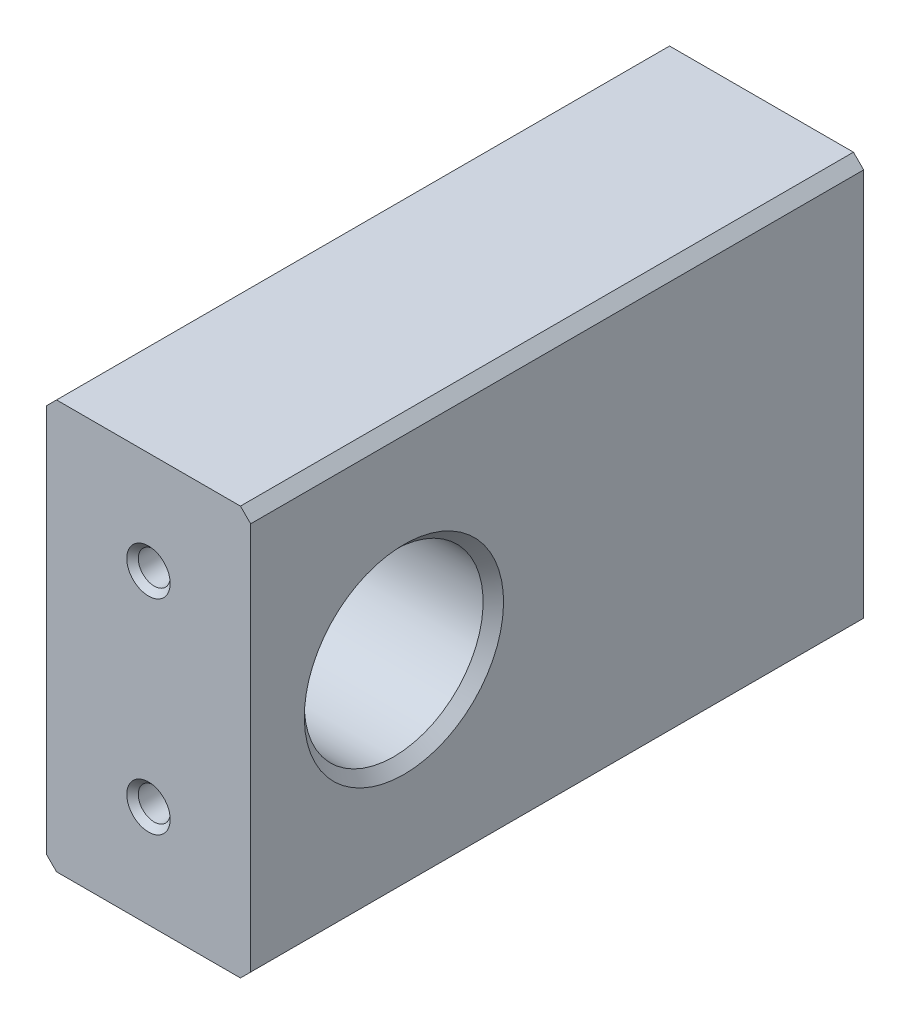
from build123d import *

# Parameters (mm, degrees)
SKETCH1_W                        = 50.8
SKETCH1_H                        = 101.6
EXTRUDE1_DEPTH                   = 152.4
SKETCH2_R                        = 22.225
EXTRUDE2_DEPTH                   = 51.8
CHAMFER1_SIZE                    = 2.54
F_3_8_16_TAPPED_HOLE1_AT_2_COUNT = 2
F_3_8_16_TAPPED_HOLE1_AT_2_PITCH = 50.8


with BuildPart() as part:
    # Sketch1 → Extrude1 (new body)
    with BuildSketch(Plane.XY):
        with Locations((25.4, 0)):
            Rectangle(SKETCH1_W, SKETCH1_H)
    extrude(amount=EXTRUDE1_DEPTH)

    # Sketch2 → Extrude2 (cut, through all)
    with BuildSketch(Plane(origin=(50.8, 0, 0), x_dir=(0, 0, -1), z_dir=(1, 0, 0))):
        with Locations(Location((-114.3, 0, 0), (0, 0, 90))):  # turned: the seam where the file's is
            Circle(SKETCH2_R)
    extrude(amount=-EXTRUDE2_DEPTH, mode=Mode.SUBTRACT)

    # Chamfer1
    chamfer1_edges = [part.edges().sort_by_distance(p)[0] for p in [
        (50.8, -22.225, 114.3),
        (50.8, -50.8, 76.2),
        (0, -50.8, 76.2),
        (0, 50.8, 76.2),
        (50.8, 50.8, 76.2),
    ]]
    chamfer(chamfer1_edges, length=CHAMFER1_SIZE)

    # Sketch3 → 3/8-16 Tapped Hole1 (revolve, cut)
    with BuildSketch(Plane(origin=(25.4, -25.4, 0), x_dir=(0, 1, 0), z_dir=(1, 0, 0))):
        Polygon((0, 0), (0, 26.260665582), (3.96875, 23.876), (3.96875, 1.42875), (5.3975, 0), align=None)
    f_3_8_16_tapped_hole1 = revolve(axis=Axis((25.4, -25.4, -6.35), (0, 0, 1)), mode=Mode.SUBTRACT)

    # 3/8-16 Tapped Hole1 at 2: 3/8-16 Tapped Hole1 ×2
    with Locations(*[(0, i * F_3_8_16_TAPPED_HOLE1_AT_2_PITCH, 0) for i in range(1, F_3_8_16_TAPPED_HOLE1_AT_2_COUNT)]):
        add(f_3_8_16_tapped_hole1, mode=Mode.SUBTRACT)

    # Mirror1: 3/8-16 Tapped Hole1 across plane
    add(f_3_8_16_tapped_hole1.mirror(Plane(origin=(0, 0, 76.2), x_dir=(1, 0, 0), z_dir=(0, 0, -1))), mode=Mode.SUBTRACT)

    # Mirror1 copy 1 sketch → Mirror1 copy 1 (revolve, cut)
    with BuildSketch(Plane(origin=(25.4, 25.4, 152.4), x_dir=(0, 1, 0), z_dir=(1, 0, 0))):
        Polygon((0, 0), (0, -26.260665582), (3.96875, -23.876), (3.96875, -1.42875), (5.3975, 0), align=None)
    revolve(axis=Axis((25.4, 25.4, 158.75), (0, 0, 1)), mode=Mode.SUBTRACT)


solid = part.part
